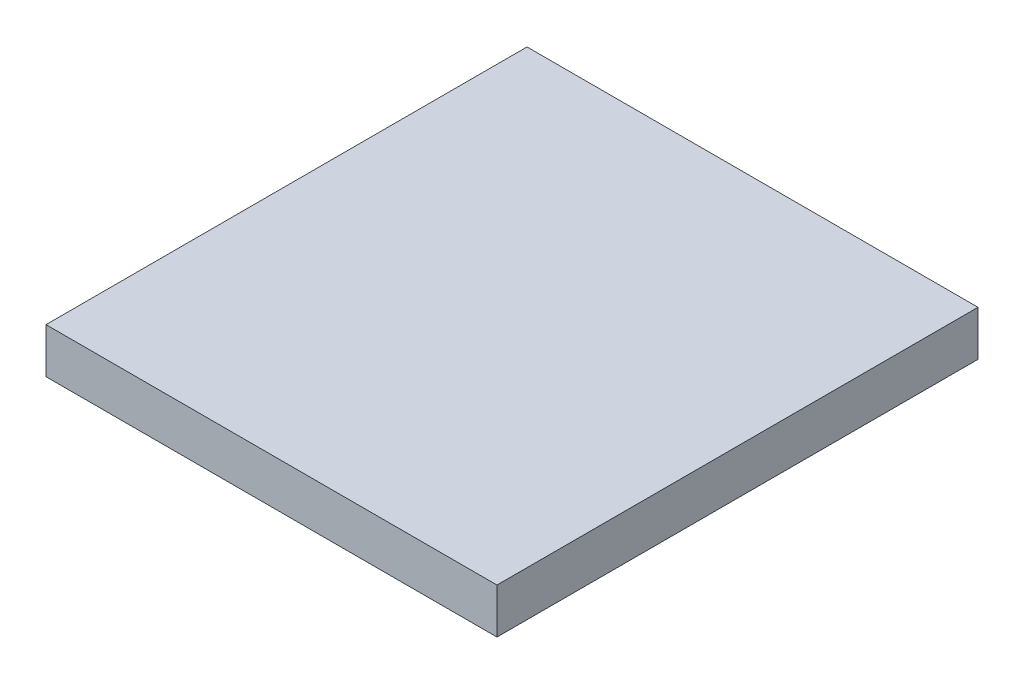
from build123d import *

# Parameters (mm, degrees)
SKETCH1_W           = 90
SKETCH1_H           = 96
BOSS_EXTRUDE1_DEPTH = 4.5


with BuildPart() as part:
    # Sketch1 → Boss-Extrude1 (new body, symmetric)
    with BuildSketch(Plane(origin=(0, 0, 0), x_dir=(1, 0, 0), z_dir=(0, 1, 0))):
        Rectangle(SKETCH1_W, SKETCH1_H)
    extrude(amount=BOSS_EXTRUDE1_DEPTH, both=True)


solid = part.part
